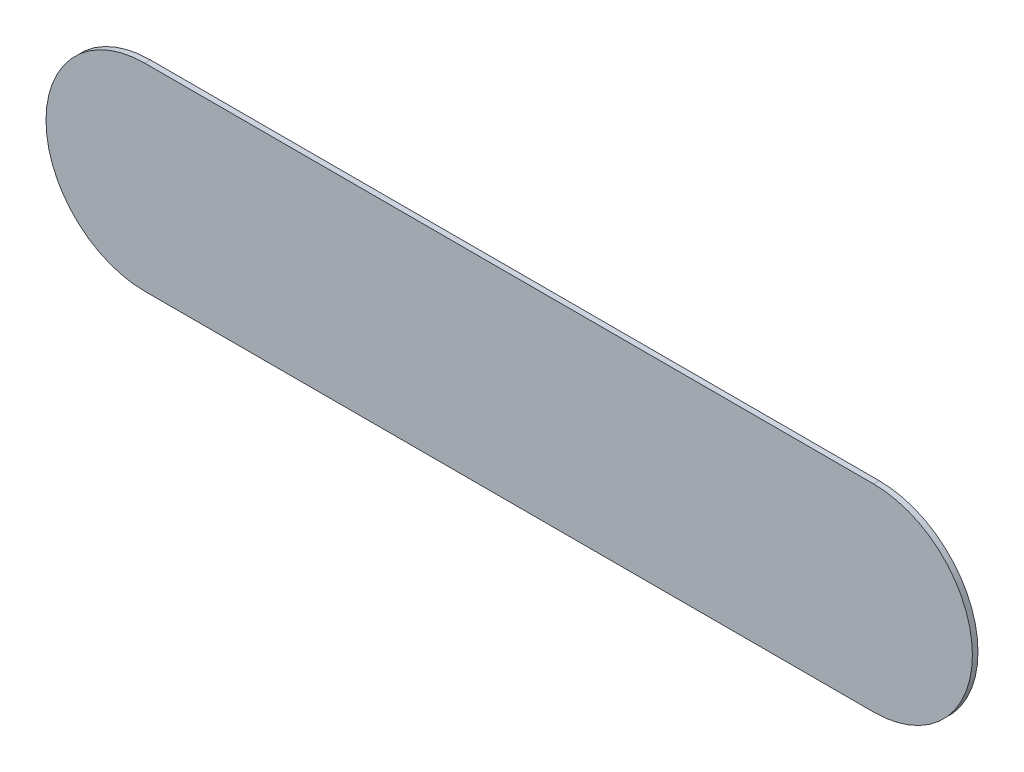
from build123d import *

# Parameters (mm, degrees)
BOSS_EXTRUDE1_DEPTH = 0.5


with BuildPart() as part:
    # Sketch1 → Boss-Extrude1 (new body)
    with BuildSketch(Plane.XY):
        with BuildLine():
            Line((0, 8.81), (65, 8.81))
            ThreePointArc((65, 8.81), (73.81, 0), (65, -8.81))
            Line((65, -8.81), (0, -8.81))
            ThreePointArc((0, -8.81), (-8.81, 0), (0, 8.81))
        make_face()
    extrude(amount=BOSS_EXTRUDE1_DEPTH)


solid = part.part
